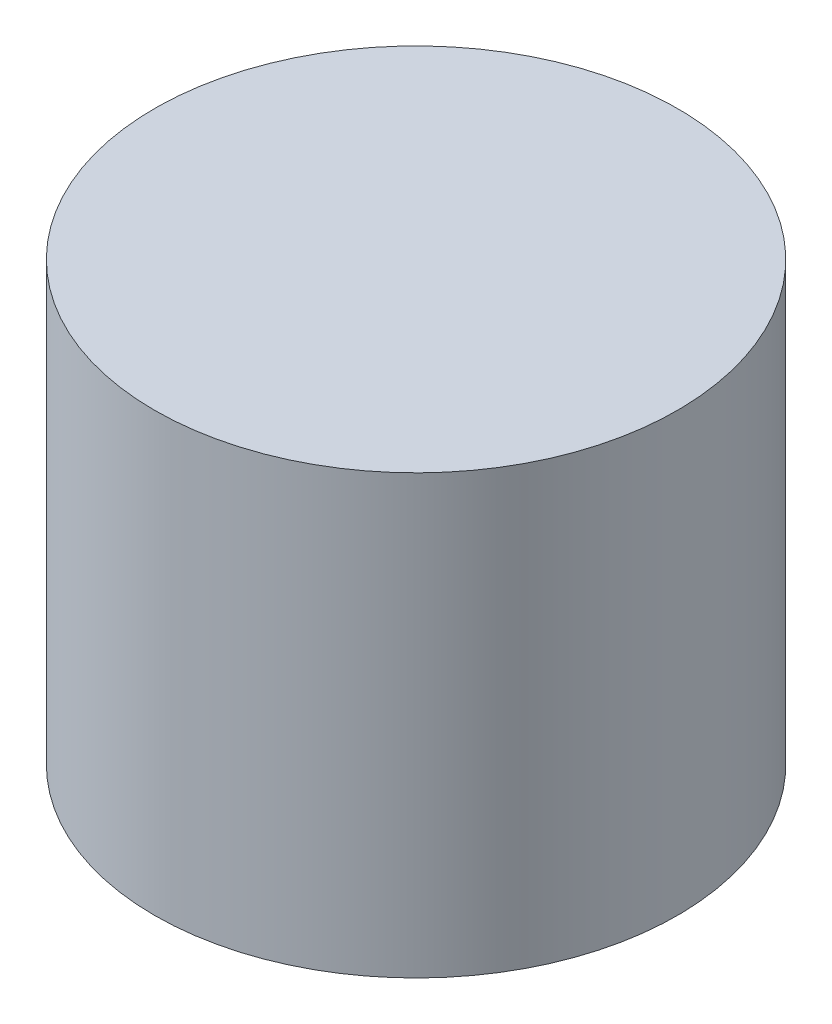
from build123d import *

# Parameters (mm, degrees)
SKETCH1_R           = 3.49
BOSS_EXTRUDE1_DEPTH = 2.92


with BuildPart() as part:
    # Sketch1 → Boss-Extrude1 (new body, symmetric)
    with BuildSketch(Plane(origin=(0, 0, 0), x_dir=(1, 0, 0), z_dir=(0, 1, 0))):
        Circle(SKETCH1_R)
    extrude(amount=BOSS_EXTRUDE1_DEPTH, both=True)


solid = part.part
